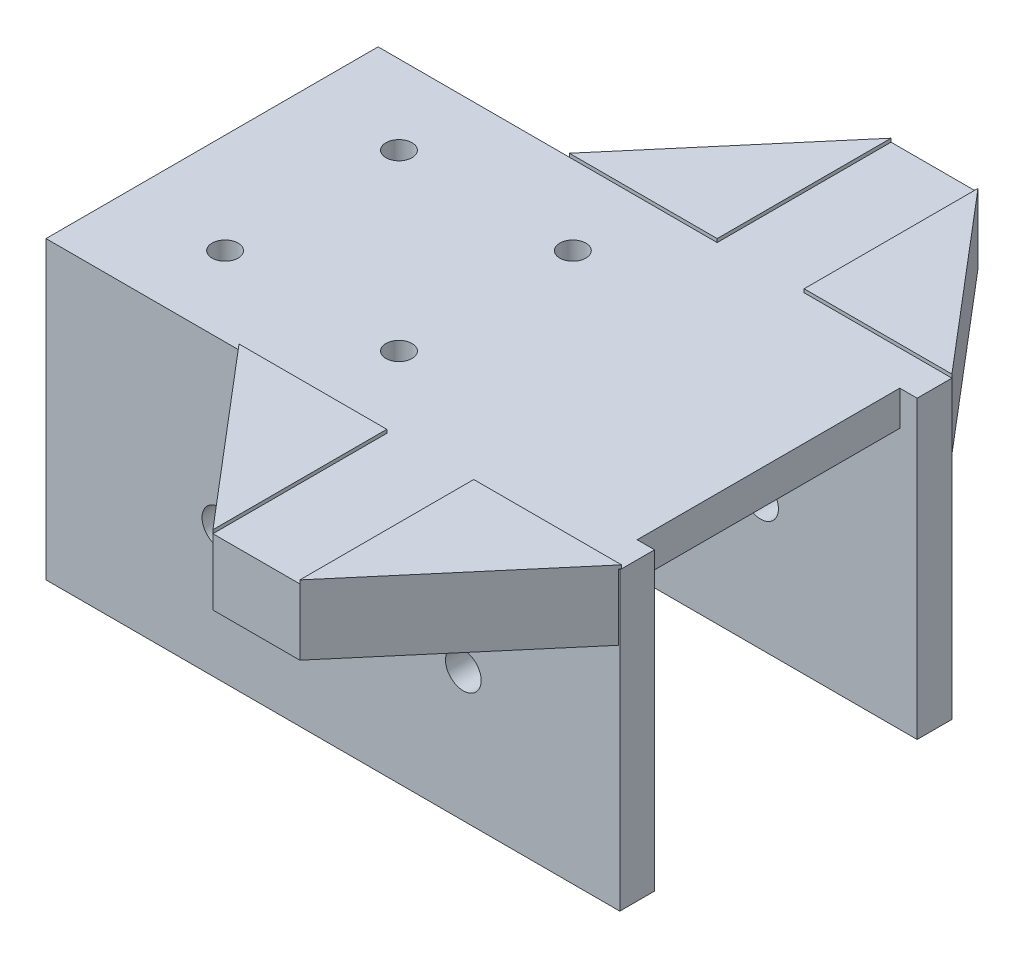
from build123d import *

# Parameters (mm, degrees)
SKIZZE1_W                                  = 60
SKIZZE1_H                                  = 30.2
SKIZZE1_R                                  = 1.5
AUFSATZ_LINEAR_AUSTRAGEN1_DEPTH            = 4
LINEAR_AUSTRAGEN_D_NN1_DEPTH               = 34
F_4_1_4_1_DURCHMESSER_BOHRUNG1_D           = 4.1
F_4_1_4_1_DURCHMESSER_BOHRUNG1_ON_FACE_2_D = 4.1
SKIZZE4_W                                  = 10
SKIZZE4_H                                  = 7.6
AUFSATZ_LINEAR_AUSTRAGEN3_DEPTH            = 20
SKIZZE5_W                                  = 1
SKIZZE5_H                                  = 2
SCHNITT_LINEAR_AUSTRAGEN1_DEPTH            = 20
AUFSATZ_LINEAR_AUSTRAGEN4_DEPTH            = 8


with BuildPart() as part:
    # Skizze1 → Aufsatz-Linear austragen1 (new body)
    with BuildSketch(Plane(origin=(0, 0, 0), x_dir=(1, 0, 0), z_dir=(0, 1, 0))):
        Rectangle(SKIZZE1_W, SKIZZE1_H)
        with Locations((-22.5, 10)):
            Circle(SKIZZE1_R, mode=Mode.SUBTRACT)
        with Locations((-22.5, -10)):
            Circle(SKIZZE1_R, mode=Mode.SUBTRACT)
        with Locations((-2.5, 10)):
            Circle(SKIZZE1_R, mode=Mode.SUBTRACT)
        with Locations((-2.5, -10)):
            Circle(SKIZZE1_R, mode=Mode.SUBTRACT)
    extrude(amount=AUFSATZ_LINEAR_AUSTRAGEN1_DEPTH)

    # Skizze2 → Linear-Austragen-Dünn1 (add)
    with BuildSketch(Plane(origin=(0, 4, 0), x_dir=(1, 0, 0), z_dir=(0, 1, 0))):
        Polygon((32, -15.1), (-30, -15.1), (-30, 15.1), (32, 15.1), (32, 19.1), (-34, 19.1), (-34, -19.1), (32, -19.1), align=None)
    extrude(amount=-LINEAR_AUSTRAGEN_D_NN1_DEPTH)

    # Ø4.1 (4.1) Durchmesser Bohrung1 (through all)
    with Locations(Plane(origin=(-14, -14.808153884, -19.1), x_dir=(-1, 0, 0), z_dir=(0, 0, -1))):
        with Locations((0, 0), (-27.999342761, -0.191846116)):
            Hole(F_4_1_4_1_DURCHMESSER_BOHRUNG1_D / 2)

    # Ø4.1 (4.1) Durchmesser Bohrung1 on face 2 (through all)
    with Locations(Plane(origin=(-34, -15, 0), x_dir=(0, 0, -1), z_dir=(-1, 0, 0))):
        with Locations((0, 0)):
            Hole(F_4_1_4_1_DURCHMESSER_BOHRUNG1_ON_FACE_2_D / 2)

    # Skizze4 → Aufsatz-Linear austragen3 (add)
    with BuildSketch(Plane(origin=(0, 0, -19.1), x_dir=(-1, 0, 0), z_dir=(0, 0, -1))):
        with Locations((-10, 0.2)):
            Rectangle(SKIZZE4_W, SKIZZE4_H)
    aufsatz_linear_austragen3 = extrude(amount=AUFSATZ_LINEAR_AUSTRAGEN3_DEPTH)

    # Skizze5 → Schnitt-Linear austragen1 (cut)
    with BuildSketch(Plane(origin=(15, 0, 0), x_dir=(0, 0, -1), z_dir=(1, 0, 0))):
        with Locations((37.6, -2.6)):
            Rectangle(SKIZZE5_W, SKIZZE5_H)
        with Locations((35.6, -2.6)):
            Rectangle(SKIZZE5_W, SKIZZE5_H)
        with Locations((33.6, -2.6)):
            Rectangle(SKIZZE5_W, SKIZZE5_H)
        with Locations((31.6, -2.6)):
            Rectangle(SKIZZE5_W, SKIZZE5_H)
        with Locations((29.6, -2.6)):
            Rectangle(SKIZZE5_W, SKIZZE5_H)
        with Locations((27.6, -2.6)):
            Rectangle(SKIZZE5_W, SKIZZE5_H)
        with Locations((25.6, -2.6)):
            Rectangle(SKIZZE5_W, SKIZZE5_H)
        with Locations((23.6, -2.6)):
            Rectangle(SKIZZE5_W, SKIZZE5_H)
        with Locations((21.6, -2.6)):
            Rectangle(SKIZZE5_W, SKIZZE5_H)
    schnitt_linear_austragen1 = extrude(amount=-SCHNITT_LINEAR_AUSTRAGEN1_DEPTH, mode=Mode.SUBTRACT)

    # Skizze6 → Aufsatz-Linear austragen4 (add)
    with BuildSketch(Plane.XZ.offset(3.6)):
        Polygon((15, -39.1), (32, -19.1), (15, -19.1), align=None)
        Polygon((5, -39.1), (5, -19.1), (-12, -19.1), align=None)
    aufsatz_linear_austragen4 = extrude(amount=-AUFSATZ_LINEAR_AUSTRAGEN4_DEPTH)

    # Spiegeln1: Aufsatz-Linear austragen3, Schnitt-Linear austragen1, Aufsatz-Linear austragen4 across plane
    add(aufsatz_linear_austragen3.mirror(Plane.XY.offset(-0.1)))
    add(schnitt_linear_austragen1.mirror(Plane.XY.offset(-0.1)), mode=Mode.SUBTRACT)
    add(aufsatz_linear_austragen4.mirror(Plane.XY.offset(-0.1)))


solid = part.part
